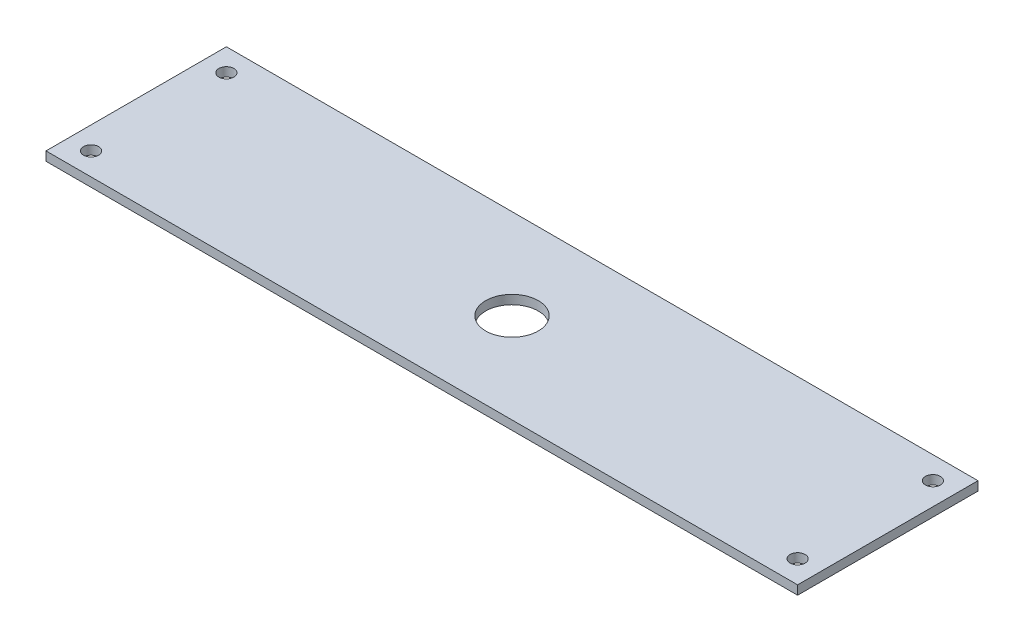
from build123d import *

# Parameters (mm, degrees)
SKETCH1_W           = 500
SKETCH1_H           = 120
SKETCH1_R           = 17.5
SKETCH1_R_2         = 5
BOSS_EXTRUDE1_DEPTH = 3


with BuildPart() as part:
    # Sketch1 → Boss-Extrude1 (new body, symmetric)
    with BuildSketch(Plane(origin=(0, 0, 0), x_dir=(1, 0, 0), z_dir=(0, 1, 0))):
        Rectangle(SKETCH1_W, SKETCH1_H)
        Circle(SKETCH1_R, mode=Mode.SUBTRACT)
        with Locations((-235, 45)):
            Circle(SKETCH1_R_2, mode=Mode.SUBTRACT)
        with Locations((-235, -45)):
            Circle(SKETCH1_R_2, mode=Mode.SUBTRACT)
        with Locations((235, 45)):
            Circle(SKETCH1_R_2, mode=Mode.SUBTRACT)
        with Locations((235, -45)):
            Circle(SKETCH1_R_2, mode=Mode.SUBTRACT)
    extrude(amount=BOSS_EXTRUDE1_DEPTH, both=True)


solid = part.part
